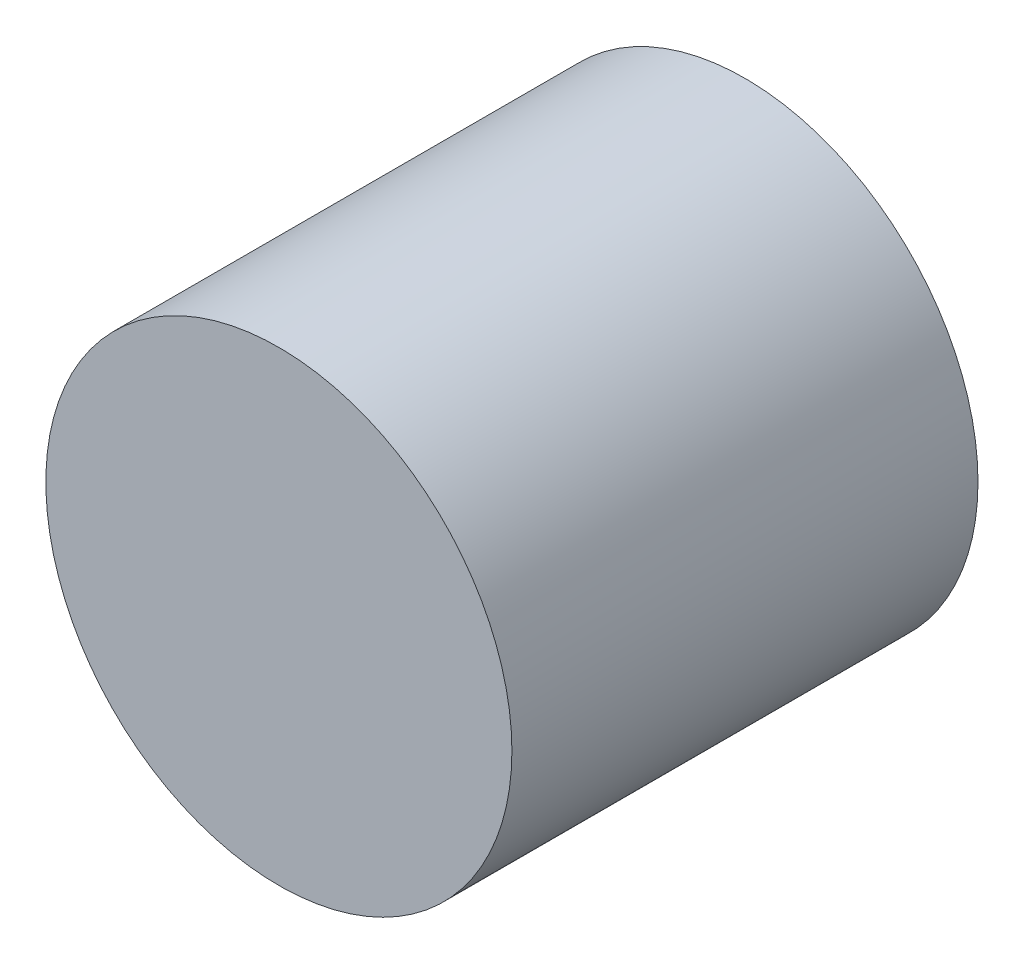
from build123d import *

# Parameters (mm, degrees)
ESQUISSE1_R        = 29
BOSS_EXTRU_1_DEPTH = 58


with BuildPart() as part:
    # Esquisse1 → Boss.-Extru.1 (new body)
    with BuildSketch(Plane.XY):
        Circle(ESQUISSE1_R)
    extrude(amount=BOSS_EXTRU_1_DEPTH)


solid = part.part
